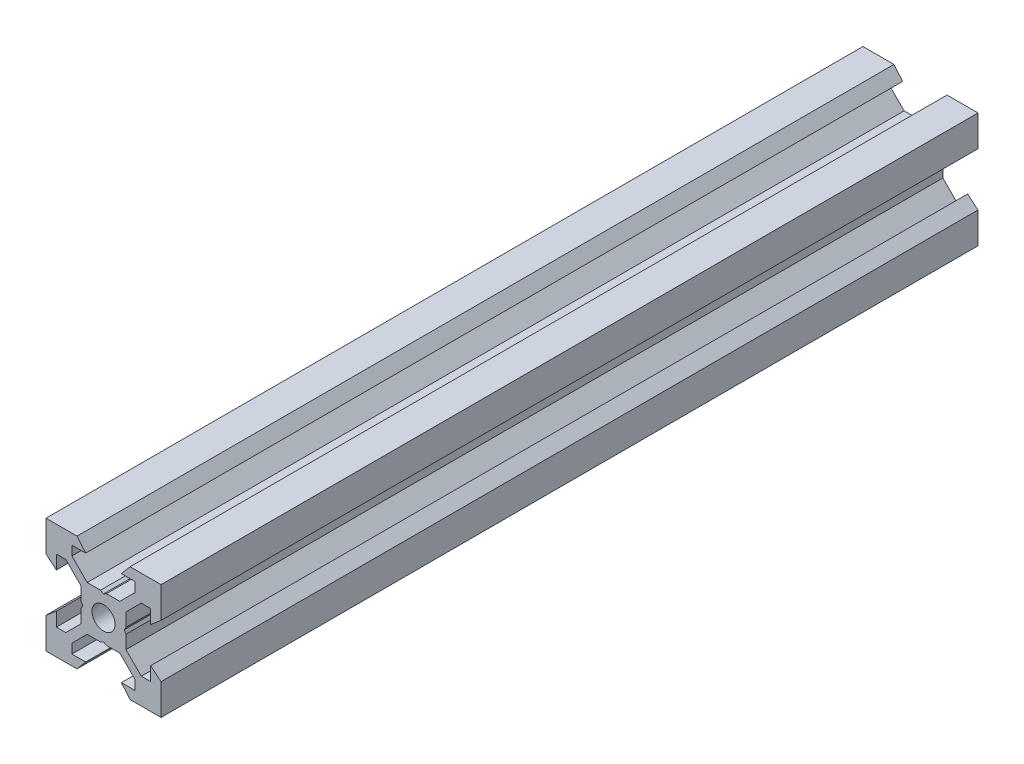
from build123d import *

# Parameters (mm, degrees)
SKETCH1_R           = 2
BOSS_EXTRUDE1_DEPTH = 71.005


with BuildPart() as part:
    # Sketch1 → Boss-Extrude1 (new body, symmetric)
    with BuildSketch(Plane.XY):
        Polygon((10, 10), (10, 4.610379336), (8.2, 3.1), (8.2, 5.5), (6.560660172, 5.5), (3.9, 2.839339828), (3.9, 0.519615242), (3.6, 0), (3.9, -0.519615242), (3.9, -2.839339828), (6.560660172, -5.5), (8.2, -5.5), (8.2, -3.1), (10, -4.610379336), (10, -10), (4.610379336, -10), (3.1, -8.2), (5.5, -8.2), (5.5, -6.560660172), (2.839339828, -3.9), (0.519615242, -3.9), (0, -3.6), (-0.519615242, -3.9), (-2.839339828, -3.9), (-5.5, -6.560660172), (-5.5, -8.2), (-3.1, -8.2), (-4.610379336, -10), (-10, -10), (-10, -4.610379336), (-8.2, -3.1), (-8.2, -5.5), (-6.560660172, -5.5), (-3.9, -2.839339828), (-3.9, -0.519615242), (-3.6, 0), (-3.9, 0.519615242), (-3.9, 2.839339828), (-6.560660172, 5.5), (-8.2, 5.5), (-8.2, 3.1), (-10, 4.610379336), (-10, 10), (-4.610379336, 10), (-3.1, 8.2), (-5.5, 8.2), (-5.5, 6.560660172), (-2.839339828, 3.9), (-0.519615242, 3.9), (0, 3.6), (0.519615242, 3.9), (2.839339828, 3.9), (5.5, 6.560660172), (5.5, 8.2), (3.1, 8.2), (4.610379336, 10), align=None)
        Circle(SKETCH1_R, mode=Mode.SUBTRACT)
    extrude(amount=BOSS_EXTRUDE1_DEPTH, both=True)


solid = part.part
